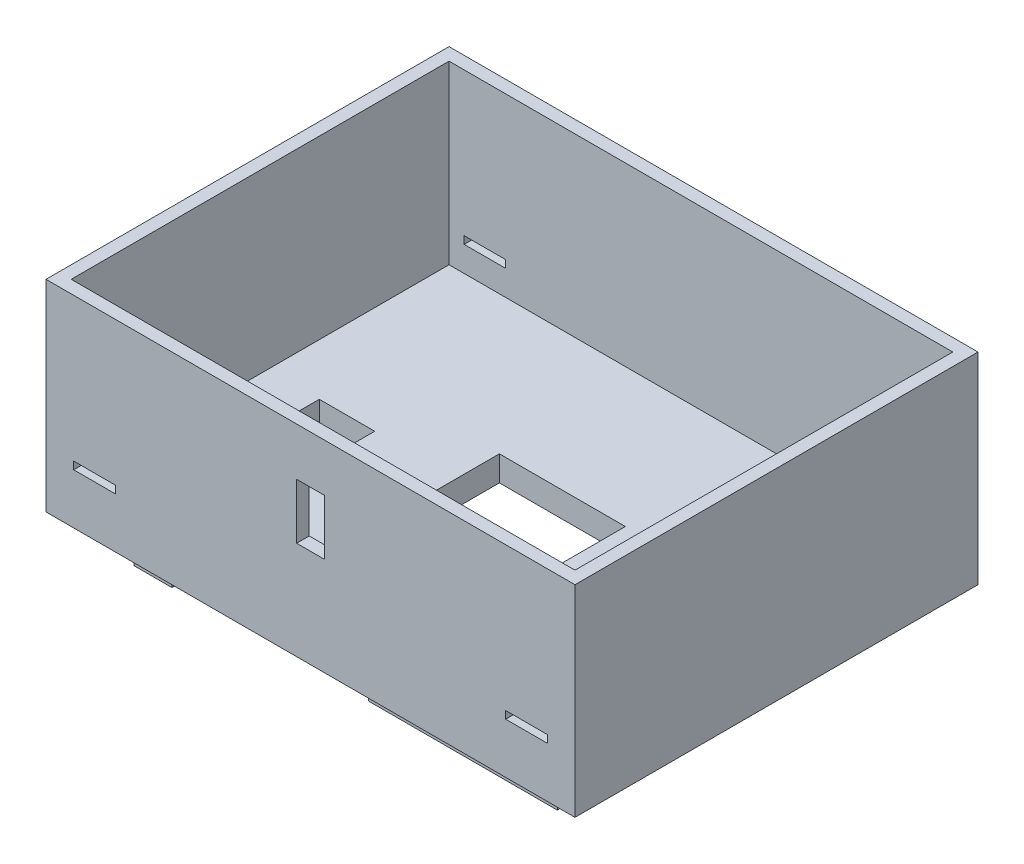
from build123d import *

# Parameters (mm, degrees)
SKETCH1_W                = 200
SKETCH1_H                = 150
SKETCH1_W_2              = 75
SKETCH1_H_2              = 5
SKETCH1_W_3              = 15
BOSS_EXTRUDE2_DEPTH      = 10
SKETCH1_8_W              = 75
SKETCH1_8_H              = 5
SKETCH1_8_W_2            = 15
BOSS_EXTRUDE3_DEPTH      = 25
BOSS_EXTRUDE4_START      = -10
BOSS_EXTRUDE4_DEPTH      = 80
SKETCH7_R                = 5
CUT_EXTRUDE2_DEPTH       = 120
CUT_EXTRUDE2_DEPTH_BACK  = 37
CUT_EXTRUDE3_DEPTH       = 142
SKETCH9_W                = 11
SKETCH9_H                = 22
CUT_EXTRUDE4_DEPTH       = 10
SKETCH15_W               = 22
SKETCH15_H               = 11
SKETCH15_W_2             = 50
SKETCH15_H_2             = 40
CUT_EXTRUDE9_DEPTH       = 10
BOSS_EXTRUDE9_START      = -10
SKETCH18_W               = 210
SKETCH18_H               = 5
BOSS_EXTRUDE9_DEPTH      = 80
SKETCH17_W               = 16.5
SKETCH17_H               = 3
CUT_EXTRUDE11_DEPTH      = 156
CUT_EXTRUDE11_DEPTH_BACK = 6


with BuildPart() as part:
    # Sketch1 → Boss-Extrude2 (new body)
    with BuildSketch(Plane(origin=(0, 0, 0), x_dir=(1, 0, 0), z_dir=(0, 1, 0))):
        Rectangle(SKETCH1_W, SKETCH1_H)
        with Locations((46.5, -63.5)):
            Rectangle(SKETCH1_W_2, SKETCH1_H_2, mode=Mode.SUBTRACT)
        with Locations((-76.5, -63.5)):
            Rectangle(SKETCH1_W_3, SKETCH1_H_2, mode=Mode.SUBTRACT)
        with Locations((-76.5, -46.5)):
            Rectangle(SKETCH1_W_3, SKETCH1_H_2, mode=Mode.SUBTRACT)
        with Locations((46.5, -46.5)):
            Rectangle(SKETCH1_W_2, SKETCH1_H_2, mode=Mode.SUBTRACT)
        with Locations((46.5, 46.5)):
            Rectangle(SKETCH1_W_2, SKETCH1_H_2, mode=Mode.SUBTRACT)
        with Locations((46.5, 63.5)):
            Rectangle(SKETCH1_W_2, SKETCH1_H_2, mode=Mode.SUBTRACT)
        with Locations((-76.5, 63.5)):
            Rectangle(SKETCH1_W_3, SKETCH1_H_2, mode=Mode.SUBTRACT)
        with Locations((-76.5, 46.5)):
            Rectangle(SKETCH1_W_3, SKETCH1_H_2, mode=Mode.SUBTRACT)
    extrude(amount=-BOSS_EXTRUDE2_DEPTH)

    # Sketch1_8 → Boss-Extrude3 (add)
    with BuildSketch(Plane(origin=(0, 0, 0), x_dir=(1, 0, 0), z_dir=(0, 1, 0))):
        with Locations((46.5, -63.5)):
            Rectangle(SKETCH1_8_W, SKETCH1_8_H)
        with Locations((-76.5, -63.5)):
            Rectangle(SKETCH1_8_W_2, SKETCH1_8_H)
        with Locations((-76.5, -46.5)):
            Rectangle(SKETCH1_8_W_2, SKETCH1_8_H)
        with Locations((46.5, -46.5)):
            Rectangle(SKETCH1_8_W, SKETCH1_8_H)
        with Locations((46.5, 46.5)):
            Rectangle(SKETCH1_8_W, SKETCH1_8_H)
        with Locations((46.5, 63.5)):
            Rectangle(SKETCH1_8_W, SKETCH1_8_H)
        with Locations((-76.5, 63.5)):
            Rectangle(SKETCH1_8_W_2, SKETCH1_8_H)
        with Locations((-76.5, 46.5)):
            Rectangle(SKETCH1_8_W_2, SKETCH1_8_H)
    extrude(amount=-BOSS_EXTRUDE3_DEPTH)

    # Sketch5 → Boss-Extrude4 (add)
    with BuildSketch(Plane(origin=(0, 0, 0), x_dir=(-1, 0, 0), z_dir=(0, 1, 0)).offset(BOSS_EXTRUDE4_START)):
        Polygon((100, 75), (100, -75), (105, -75), (105, 70.097096622), (105, 80), (-105, 80), (-105, 70.097096622), (-105, -75), (-100, -75), (-100, 75), align=None)
    extrude(amount=BOSS_EXTRUDE4_DEPTH)

    # Sketch7 → Cut-Extrude2 (cut, two sides)
    with BuildSketch(Plane(origin=(0, 0, 44), x_dir=(-1, 0, 0), z_dir=(0, 0, -1))) as cut_extrude2_sk:
        with Locations((76.5, -17.5)):
            Circle(SKETCH7_R)
    extrude(amount=CUT_EXTRUDE2_DEPTH, mode=Mode.SUBTRACT)
    extrude(cut_extrude2_sk.sketch, amount=-CUT_EXTRUDE2_DEPTH_BACK, mode=Mode.SUBTRACT)

    # Sketch8 → Cut-Extrude3 (cut, through all)
    with BuildSketch(Plane.XY.offset(66)):
        with BuildLine():
            Line((16.5, -12.5), (76.5, -12.5))
            ThreePointArc((76.5, -12.5), (81.5, -17.5), (76.5, -22.5))
            Line((76.5, -22.5), (16.5, -22.5))
            ThreePointArc((16.5, -22.5), (11.5, -17.5), (16.5, -12.5))
        make_face()
    extrude(amount=-CUT_EXTRUDE3_DEPTH, mode=Mode.SUBTRACT)

    # Sketch9 → Cut-Extrude4 (cut)
    with BuildSketch(Plane.XY.offset(80)):
        with Locations((0, 40)):
            Rectangle(SKETCH9_W, SKETCH9_H)
    extrude(amount=-CUT_EXTRUDE4_DEPTH, mode=Mode.SUBTRACT)

    # Sketch15 → Cut-Extrude9 (cut)
    with BuildSketch(Plane.XZ.offset(10)):
        with Locations((-68.5, 2.5)):
            Rectangle(SKETCH15_W, SKETCH15_H)
        with Locations((68.5, 2.5)):
            Rectangle(SKETCH15_W, SKETCH15_H)
        Rectangle(SKETCH15_W_2, SKETCH15_H_2)
    extrude(amount=-CUT_EXTRUDE9_DEPTH, mode=Mode.SUBTRACT)

    # Sketch18 → Boss-Extrude9 (add)
    with BuildSketch(Plane(origin=(0, 0, 0), x_dir=(1, 0, 0), z_dir=(0, 1, 0)).offset(BOSS_EXTRUDE9_START)):
        with Locations((0, 77.5)):
            Rectangle(SKETCH18_W, SKETCH18_H)
    extrude(amount=BOSS_EXTRUDE9_DEPTH)

    # Sketch17 → Cut-Extrude11 (cut, two sides)
    with BuildSketch(Plane(origin=(0, 0, 75), x_dir=(-1, 0, 0), z_dir=(0, 0, -1))) as cut_extrude11_sk:
        with Locations((-85.75, 11.5)):
            Rectangle(SKETCH17_W, SKETCH17_H)
        with Locations((85.75, 11.5)):
            Rectangle(SKETCH17_W, SKETCH17_H)
    extrude(amount=CUT_EXTRUDE11_DEPTH, mode=Mode.SUBTRACT)
    extrude(cut_extrude11_sk.sketch, amount=-CUT_EXTRUDE11_DEPTH_BACK, mode=Mode.SUBTRACT)


solid = part.part
